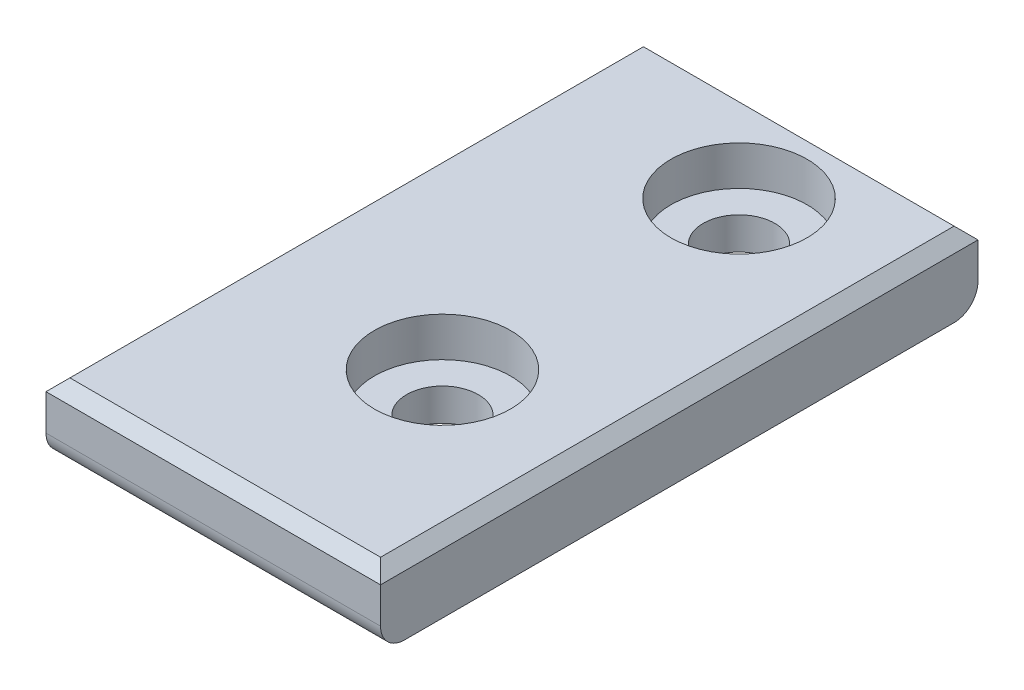
from build123d import *

# Parameters (mm, degrees)
SKETCH1_W           = 14
SKETCH1_H           = 25
SKETCH1_R           = 1.5
BOSS_EXTRUDE1_DEPTH = 3
CHAMFER1_SIZE       = 0.5
FILLET1_R           = 1
SKETCH2_R           = 2.85
CUT_EXTRUDE1_DEPTH  = 1.65
BOSS_EXTRUDE2_START = -1
BOSS_EXTRUDE2_DEPTH = 1


with BuildPart() as part:
    # Sketch1 → Boss-Extrude1 (new body)
    with BuildSketch(Plane(origin=(0, 0, 0), x_dir=(1, 0, 0), z_dir=(0, 1, 0))):
        with Locations((7, 12.5)):
            Rectangle(SKETCH1_W, SKETCH1_H)
        with Locations((8, 21)):
            Circle(SKETCH1_R, mode=Mode.SUBTRACT)
        with Locations((8, 8.5895)):
            Circle(SKETCH1_R, mode=Mode.SUBTRACT)
    extrude(amount=BOSS_EXTRUDE1_DEPTH)

    # Chamfer1
    chamfer1_edges = [part.edges().sort_by_distance(p)[0] for p in [
        (14, 3, -12.5),
        (7, 3, -25),
        (0, 3, -12.5),
        (7, 3, 0),
    ]]
    chamfer(chamfer1_edges, length=CHAMFER1_SIZE)

    # Fillet1
    fillet1_edges = [part.edges().sort_by_distance(p)[0] for p in [
        (7, 0, -25),
        (7, 0, 0),
    ]]
    fillet(fillet1_edges, radius=FILLET1_R)

    # Sketch2 → Cut-Extrude1 (cut)
    with BuildSketch(Plane(origin=(0, 3, 0), x_dir=(1, 0, 0), z_dir=(0, 1, 0))):
        with Locations((8, 21)):
            Circle(SKETCH2_R)
        with Locations((8, 8.5895)):
            Circle(SKETCH2_R)
    extrude(amount=-CUT_EXTRUDE1_DEPTH, mode=Mode.SUBTRACT)

    # Sketch3 → Boss-Extrude2 (add)
    with BuildSketch(Plane.XZ.offset(BOSS_EXTRUDE2_START)):
        with BuildLine():
            ThreePointArc((4.5, -24), (4.792893219, -24.707106781), (5.5, -25))
            Line((5.5, -25), (10.5, -25))
            ThreePointArc((10.5, -25), (11.207106781, -24.707106781), (11.5, -24))
            Line((11.5, -24), (4.5, -24))
        make_face()
    extrude(amount=BOSS_EXTRUDE2_DEPTH)


solid = part.part
